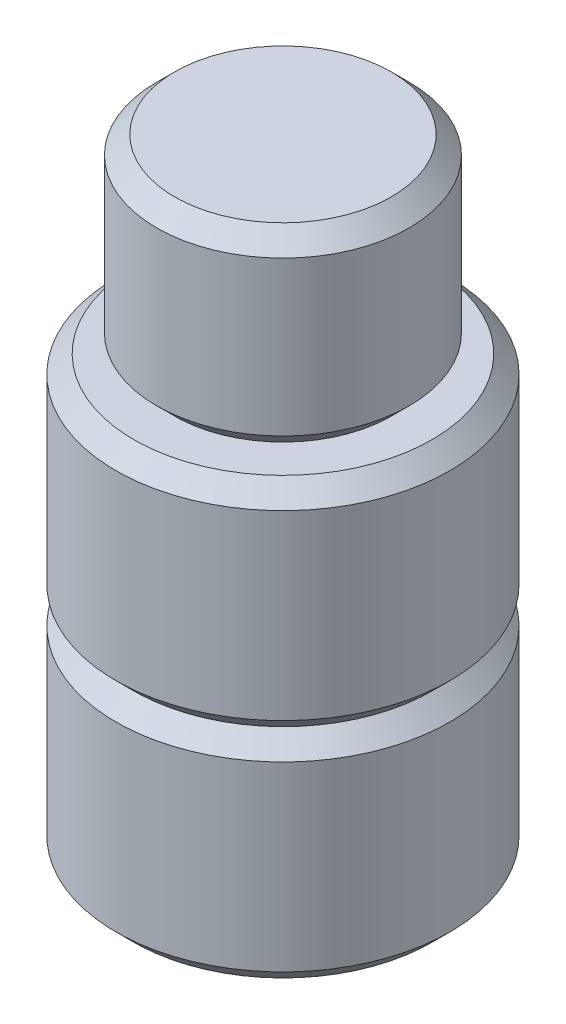
from build123d import *


with BuildPart() as part:
    # Sketch1 → Revolve1 (revolve)
    with BuildSketch(Plane.XY):
        Polygon((0, 0), (16.65, 0), (18.65, 2), (18.65, 22.31), (16.65, 24.31), (18.65, 26.31), (18.65, 46.62), (16.65, 48.62), (12.1, 48.62), (14.1, 50.62), (14.1, 67.83), (12.1, 69.83), (0, 69.83), align=None)
    revolve(axis=Axis((0, 0, 0), (0, 1, 0)))


solid = part.part
